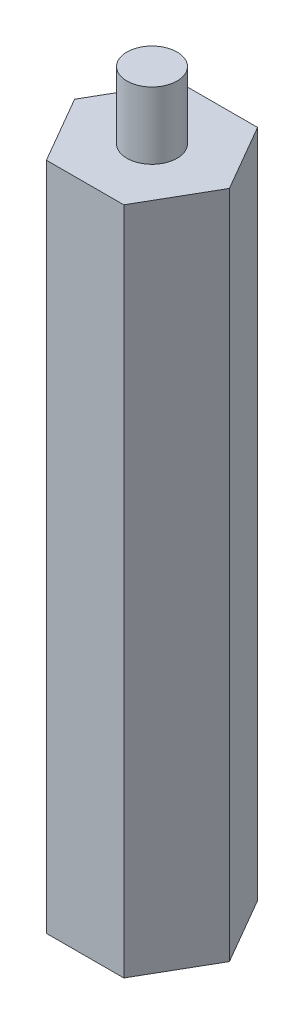
from build123d import *

# Parameters (mm, degrees)
EXTRUDE_1_DEPTH     = 80
SKETCH_2_R          = 3
EXTRUDE_2_DEPTH     = 8
SKETCH_3_R          = 3
CUT_EXTRUDE_1_DEPTH = 8


with BuildPart() as part:
    # 草图1 → 凸台-拉伸1 (new body)
    with BuildSketch(Plane(origin=(0, 0, 0), x_dir=(1, 0, 0), z_dir=(0, 1, 0))):
        Polygon((4.610693432, 8.004676097), (-4.626906133, 7.995315689), (-9.237599565, -0.009360407), (-4.610693432, -8.004676097), (4.626906133, -7.995315689), (9.237599565, 0.009360407), align=None)
    extrude(amount=EXTRUDE_1_DEPTH)

    # 草图2 → 凸台-拉伸2 (add)
    with BuildSketch(Plane(origin=(0, 80, 0), x_dir=(1, 0, 0), z_dir=(0, 1, 0))):
        Circle(SKETCH_2_R)
    extrude(amount=EXTRUDE_2_DEPTH)

    # 草图3 → 切除-拉伸1 (cut)
    with BuildSketch(Plane.XZ):
        Circle(SKETCH_3_R)
    extrude(amount=-CUT_EXTRUDE_1_DEPTH, mode=Mode.SUBTRACT)


solid = part.part
